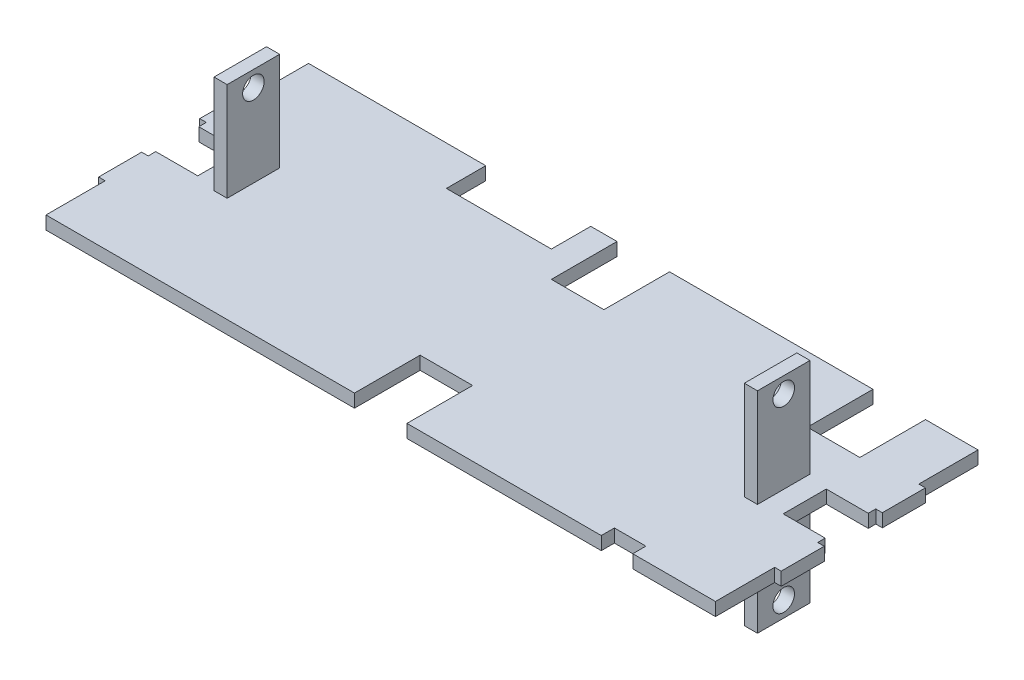
from build123d import *

# Parameters (mm, degrees)
BOSS_EXTRUDE1_DEPTH     = 3.175
SKETCH2_W               = 6.35
SKETCH2_H               = 25.4
BOSS_EXTRUDE2_DEPTH     = 50.8
SKETCH3_R               = 5.207
CUT_EXTRUDE1_DEPTH      = 34.655
CUT_EXTRUDE1_DEPTH_BACK = 297.545
SKETCH4_W               = 50.8
SKETCH4_H               = 19.05
CUT_EXTRUDE2_DEPTH      = 54.975


with BuildPart() as part:
    # Sketch1 → Boss-Extrude1 (new body, symmetric)
    with BuildSketch(Plane(origin=(0, 0, 0), x_dir=(1, 0, 0), z_dir=(0, 1, 0))):
        Polygon((-136.779, 63.5), (-111.379, 63.5), (-12.7, 63.5), (-12.7, 31.75), (12.7, 31.75), (12.7, 63.5), (111.125, 63.5), (111.125, 31.75), (136.525, 31.75), (136.525, 63.5), (161.925, 63.5), (161.925, 34.874677354), (165.1, 34.874677354), (165.1, 14.046677354), (161.925, 14.046677354), (161.925, 10.414), (141.605, 10.414), (141.605, -10.414), (161.925, -10.414), (161.925, -14.046677354), (165.1, -14.046677354), (165.1, -34.874677354), (161.925, -34.874677354), (161.925, -63.5), (121.92, -63.5), (121.92, -57.15), (106.68, -57.15), (106.68, -63.5), (12.7, -63.5), (12.7, -31.75), (-12.7, -31.75), (-12.7, -63.5), (-106.68, -63.5), (-110.5408, -63.5), (-135.9408, -63.5), (-161.925, -63.5), (-161.925, -34.874677354), (-165.1, -34.874677354), (-165.1, -14.046677354), (-161.925, -14.046677354), (-161.925, -10.414), (-141.605, -10.414), (-141.605, 10.414), (-161.925, 10.414), (-161.925, 14.046677354), (-165.1, 14.046677354), (-165.1, 34.874677354), (-161.925, 34.874677354), (-161.925, 63.5), align=None)
    extrude(amount=BOSS_EXTRUDE1_DEPTH, both=True)

    # Sketch2 → Boss-Extrude2 (add, symmetric)
    with BuildSketch(Plane(origin=(0, 0, 0), x_dir=(1, 0, 0), z_dir=(0, 1, 0))):
        with Locations((128.27, 0)):
            Rectangle(SKETCH2_W, SKETCH2_H)
        with Locations((-128.27, 0)):
            Rectangle(SKETCH2_W, SKETCH2_H)
    extrude(amount=BOSS_EXTRUDE2_DEPTH, both=True)

    # Sketch3 → Cut-Extrude1 (cut, two sides)
    with BuildSketch(Plane.ZY.offset(131.445)) as cut_extrude1_sk:
        with Locations((0, 43.18)):
            Circle(SKETCH3_R)
        with Locations((0, -43.18)):
            Circle(SKETCH3_R)
    extrude(amount=CUT_EXTRUDE1_DEPTH, mode=Mode.SUBTRACT)
    extrude(cut_extrude1_sk.sketch, amount=-CUT_EXTRUDE1_DEPTH_BACK, mode=Mode.SUBTRACT)

    # Sketch4 → Cut-Extrude2 (cut, through all)
    with BuildSketch(Plane(origin=(0, 3.175, 0), x_dir=(1, 0, 0), z_dir=(0, 1, 0))):
        with Locations((-50.8, 53.975)):
            Rectangle(SKETCH4_W, SKETCH4_H)
    extrude(amount=-CUT_EXTRUDE2_DEPTH, mode=Mode.SUBTRACT)


solid = part.part
